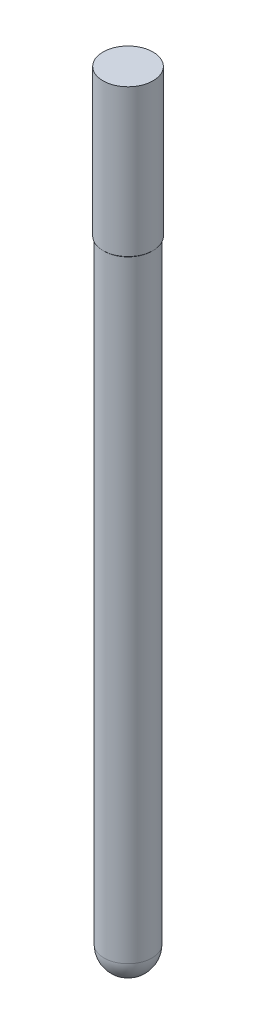
from build123d import *


with BuildPart() as part:
    # Sketch1 → Revolve1 (revolve)
    with BuildSketch(Plane.XY):
        with BuildLine():
            Line((0, 0), (0, 80))
            Line((0, 80), (2.5, 80))
            Line((2.5, 80), (2.55, 80))
            Line((2.55, 80), (2.55, 65))
            Line((2.55, 65), (2.45, 64.9))
            Line((2.45, 64.9), (2.45, 2.45))
            ThreePointArc((2.45, 2.45), (1.732411614, 0.717588386), (0, 0))
        make_face()
    revolve(axis=Axis((0, 0, 0), (0, 1, 0)))


solid = part.part
